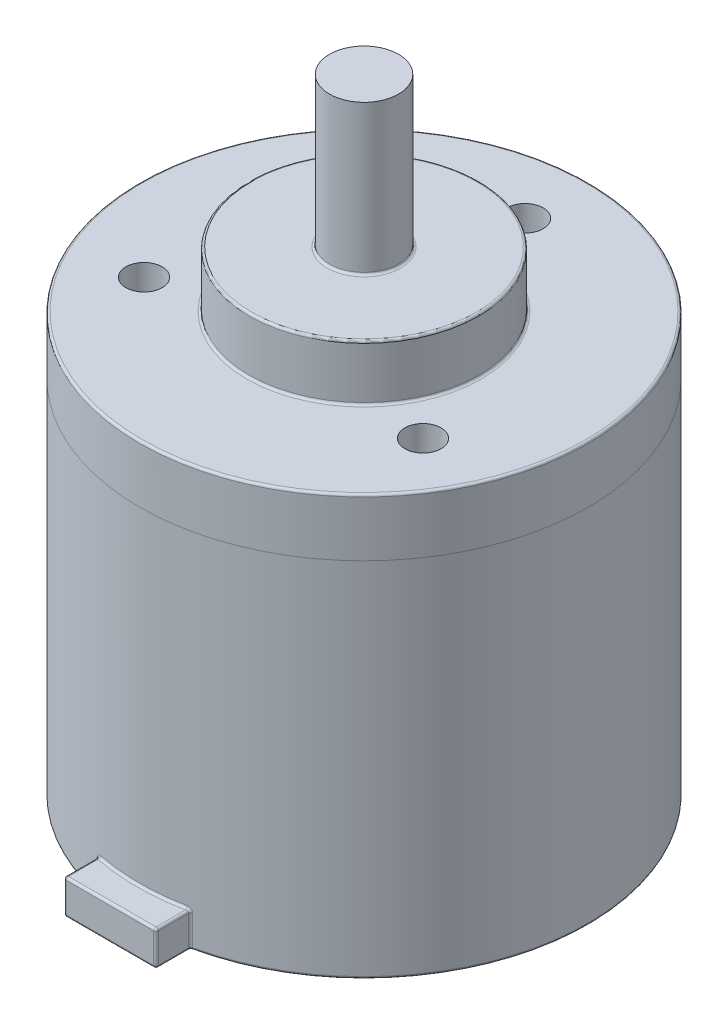
from build123d import *

# Parameters (mm, degrees)
SKETCH1_R           = 19.5
BOSS_EXTRUDE1_DEPTH = 36.5
SKETCH2_R           = 10
BOSS_EXTRUDE2_DEPTH = 4.85
SKETCH2_2_R         = 10
BOSS_EXTRUDE3_DEPTH = 4.85
SKETCH5_R           = 3
BOSS_EXTRUDE4_DEPTH = 13
CIRPATTERN1_COUNT   = 3
BOSS_EXTRUDE5_DEPTH = 3
FILLET1_R           = 0.2
FILLET2_R           = 0.2


with BuildPart() as part:
    # Sketch1 → Boss-Extrude1 (new body)
    with BuildSketch(Plane(origin=(0, 0, 0), x_dir=(1, 0, 0), z_dir=(0, 1, 0))):
        Circle(SKETCH1_R)
    extrude(amount=BOSS_EXTRUDE1_DEPTH)

    # Sketch2 → Boss-Extrude2 (add)
    with BuildSketch(Plane(origin=(0, 36.5, 0), x_dir=(1, 0, 0), z_dir=(0, 1, 0))):
        Circle(SKETCH2_R)
    extrude(amount=BOSS_EXTRUDE2_DEPTH)

    # Sketch2_2 → Boss-Extrude3 (add)
    with BuildSketch(Plane(origin=(0, 36.5, 0), x_dir=(1, 0, 0), z_dir=(0, 1, 0))):
        Circle(SKETCH2_2_R)
    extrude(amount=BOSS_EXTRUDE3_DEPTH)

    # Sketch5 → Boss-Extrude4 (add)
    with BuildSketch(Plane(origin=(0, 41.35, 0), x_dir=(1, 0, 0), z_dir=(0, 1, 0))):
        Circle(SKETCH5_R)
    extrude(amount=BOSS_EXTRUDE4_DEPTH)

    # Sketch14 → Tap Drill for M3 Helicoil1 (revolve, cut)
    with BuildSketch(Plane(origin=(0, 36.5, -14), x_dir=(0, 0, 1), z_dir=(1, 0, 0))):
        Polygon((0, 0), (0, 5.946355475), (1.575, 5), (1.575, 0), align=None)
    tap_drill_for_m3_helicoil1 = revolve(axis=Axis((0, 42.85, -14), (0, -1, 0)), mode=Mode.SUBTRACT)

    # CirPattern1: Tap Drill for M3 Helicoil1 ×3 about axis
    cirpattern1_axis = Axis((0, 36.5, 0), (0, 1, 0))
    for i in range(1, CIRPATTERN1_COUNT):
        add(tap_drill_for_m3_helicoil1.rotate(cirpattern1_axis, i * 360 / CIRPATTERN1_COUNT), mode=Mode.SUBTRACT)

    # Sketch15 → Boss-Extrude5 (add)
    with BuildSketch(Plane.XZ):
        with BuildLine():
            Line((-4, 19.085334684), (-4, 22.085334684))
            Line((-4, 22.085334684), (4, 22.085334684))
            Line((4, 22.085334684), (4, 19.085334684))
            ThreePointArc((4, 19.085334684), (0, 19.5), (-4, 19.085334684))
        make_face()
    extrude(amount=-BOSS_EXTRUDE5_DEPTH)

    # Fillet1
    fillet1_edges = [part.edges().sort_by_distance(p)[0] for p in [
        (0, 3, 19.5),
        (-12.293290853, 0, -15.136875503),
        (4, 3, 20.585334684),
        (4, 1.5, 19.085334684),
        (4, 0, 20.585334684),
        (-4, 1.5, 19.085334684),
        (-4, 3, 20.585334684),
        (-4, 0, 20.585334684),
        (-4, 1.5, 22.085334684),
        (0, 3, 22.085334684),
        (4, 1.5, 22.085334684),
        (0, 0, 22.085334684),
    ]]
    fillet(fillet1_edges, radius=FILLET1_R)

    # Fillet2
    fillet2_edges = [part.edges().sort_by_distance(p)[0] for p in [
        (-3, 41.35, 0),
        (-10, 41.35, 0),
        (-10, 36.5, 0),
        (-19.5, 36.5, 0),
    ]]
    fillet(fillet2_edges, radius=FILLET2_R)


solid = part.part
